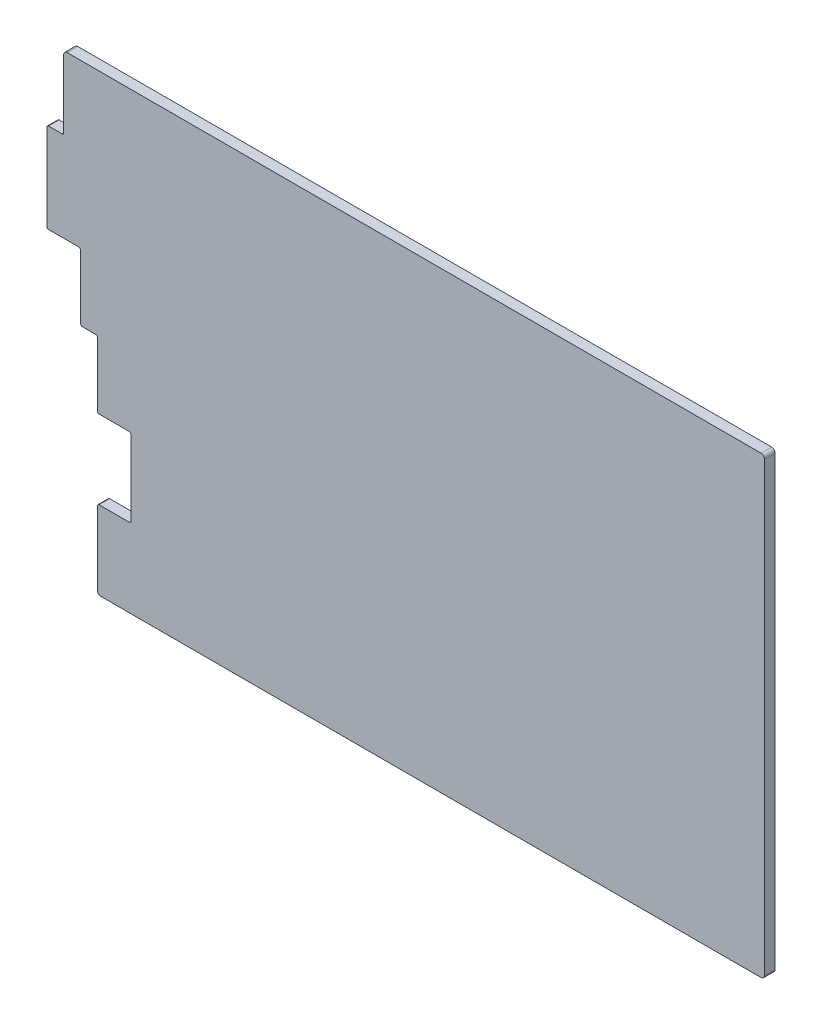
from build123d import *

# Parameters (mm, degrees)
EXTRUDE_1_DEPTH = 3
FILLET_1_R      = 0.5
FILLET_2_R      = 1


with BuildPart() as part:
    # Model → 凸台-拉伸1 (new body)
    with BuildSketch(Plane.XY):
        Polygon((204.883, 129.021), (6.45693, 129.021), (6.45693, 108.371), (1.69393, 108.371), (1.69393, 82.991), (11.21893, 82.991), (11.21893, 63.941), (15.98193, 63.941), (15.98193, 44.891), (25.50693, 44.891), (25.50693, 22.641), (15.98193, 22.641), (15.98193, 0.434082), (204.883, 0.434082), align=None)
    extrude(amount=EXTRUDE_1_DEPTH)

    # 圆角1
    fillet_1_edges = [part.edges().sort_by_distance(p)[0] for p in [
        (15.98193, 22.641, 1.5),
        (25.50693, 22.641, 1.5),
        (25.50693, 44.891, 1.5),
        (15.98193, 44.891, 1.5),
        (15.98193, 63.941, 1.5),
        (11.21893, 63.941, 1.5),
        (11.21893, 82.991, 1.5),
        (1.69393, 82.991, 1.5),
        (1.69393, 108.371, 1.5),
        (6.45693, 108.371, 1.5),
    ]]
    fillet(fillet_1_edges, radius=FILLET_1_R)

    # 圆角2
    fillet_2_edges = [part.edges().sort_by_distance(p)[0] for p in [
        (6.45693, 129.021, 1.5),
        (204.883, 129.021, 1.5),
        (204.883, 0.434082, 1.5),
        (15.98193, 0.434082, 1.5),
    ]]
    fillet(fillet_2_edges, radius=FILLET_2_R)


solid = part.part
